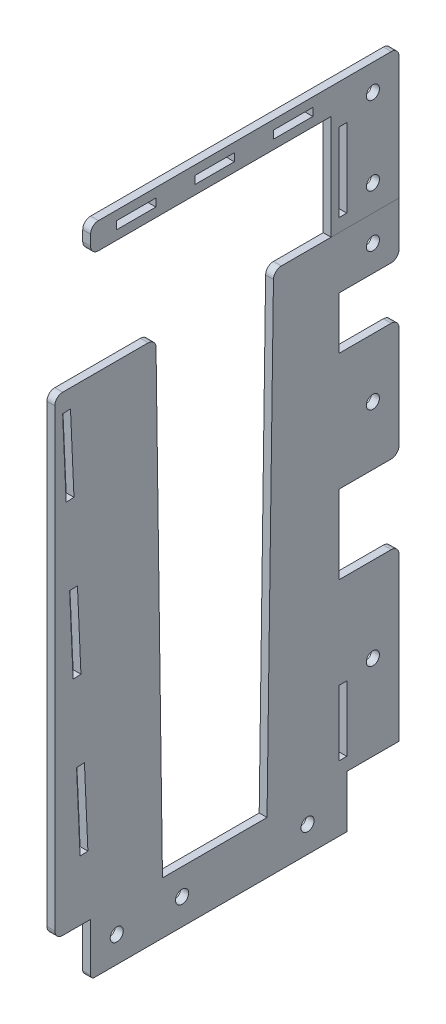
from build123d import *

# Parameters (mm, degrees)
SKETCH1_R           = 2.5
SKETCH1_W           = 3
SKETCH1_H           = 25
BOSS_EXTRUDE1_DEPTH = 3
SKETCH4_W           = 15
SKETCH4_H           = 3
BOSS_EXTRUDE2_DEPTH = 3
SKETCH5_W           = 13.685275767
SKETCH5_H           = 180
BOSS_EXTRUDE3_DEPTH = 3
CUT_EXTRUDE3_DEPTH  = 4
FILLET1_R           = 3
SKETCH12_R          = 2.5
CUT_EXTRUDE7_DEPTH  = 4
FILLET2_R           = 1.5
SKETCH13_R          = 2.5
CUT_EXTRUDE8_DEPTH  = 4
SKETCH15_R          = 2.5
CUT_EXTRUDE9_DEPTH  = 10
SKETCH17_W          = 3
SKETCH17_H          = 30
CUT_EXTRUDE10_DEPTH = 4
SKETCH16_W          = 3
SKETCH16_H          = 40
BOSS_EXTRUDE4_DEPTH = 3
FILLET3_R           = 3


with BuildPart() as part:
    # Sketch1 → Boss-Extrude1 (new body)
    with BuildSketch(Plane(origin=(0, 0, 0), x_dir=(0, 0, -1), z_dir=(1, 0, 0))):
        Polygon((0, 0), (-98, 0), (-98, 200), (20, 200), (20, 180), (-3, 180), (-3, 160), (20, 160), (20, 115), (-3, 115), (-3, 85), (20, 85), (20, 20), (0, 20), align=None)
        with Locations((10, 190)):
            Circle(SKETCH1_R, mode=Mode.SUBTRACT)
        with Locations((10, 137.5)):
            Circle(SKETCH1_R, mode=Mode.SUBTRACT)
        with Locations((10, 52.5)):
            Circle(SKETCH1_R, mode=Mode.SUBTRACT)
        with Locations((-1.5, 37.5)):
            Rectangle(SKETCH1_W, SKETCH1_H, mode=Mode.SUBTRACT)
    extrude(amount=BOSS_EXTRUDE1_DEPTH)

    # Sketch5 → Boss-Extrude3 (add)
    with BuildSketch(Plane(origin=(3, 0, 0), x_dir=(0, 0, -1), z_dir=(1, 0, 0))):
        with Locations((-104.842637884, 110)):
            Rectangle(SKETCH5_W, SKETCH5_H)
        Polygon((-105.688234347, 192.985272811), (-108.685275767, 192.85207097), (-107.353257358, 162.881656776), (-104.356215939, 163.014858617), align=None, mode=Mode.SUBTRACT)
        Polygon((-103.02419753, 133.044444423), (-106.021238949, 132.911242582), (-104.689220541, 102.940828388), (-101.692179121, 103.074030229), align=None, mode=Mode.SUBTRACT)
        Polygon((-100.360160713, 73.103616035), (-103.357202132, 72.970414194), (-102.025183723, 43), (-99.028142304, 43.133201841), align=None, mode=Mode.SUBTRACT)
    extrude(amount=-BOSS_EXTRUDE3_DEPTH)

    # Sketch6 → Cut-Extrude3 (cut)
    with BuildSketch(Plane(origin=(3, 0, 0), x_dir=(0, 0, -1), z_dir=(1, 0, 0))):
        Polygon((-28, 200), (-73, 200), (-70.5, 20), (-30.5, 20), align=None)
    extrude(amount=-CUT_EXTRUDE3_DEPTH, mode=Mode.SUBTRACT)

    # Fillet1
    fillet1_edges = [part.edges().sort_by_distance(p)[0] for p in [
        (1.5, 200, 28),
        (1.5, 200, 73),
        (1.5, 180, -20),
        (1.5, 160, -20),
        (1.5, 115, -20),
        (1.5, 85, -20),
        (1.5, 20, 111.685275767),
        (1.5, 200, 111.685275767),
    ]]
    fillet(fillet1_edges, radius=FILLET1_R)

    # Sketch12 → Cut-Extrude7 (cut)
    with BuildSketch(Plane(origin=(3, 0, 0), x_dir=(0, 0, -1), z_dir=(1, 0, 0))):
        with Locations((-88, 10)):
            Circle(SKETCH12_R)
    extrude(amount=-CUT_EXTRUDE7_DEPTH, mode=Mode.SUBTRACT)

    # Fillet2
    fillet2_edges = [part.edges().sort_by_distance(p)[0] for p in [
        (1.5, 0, 98),
    ]]
    fillet(fillet2_edges, radius=FILLET2_R)

    # Sketch13 → Cut-Extrude8 (cut, through all)
    with BuildSketch(Plane(origin=(3, 0, 0), x_dir=(0, 0, -1), z_dir=(1, 0, 0))):
        with Locations((-63, 10)):
            Circle(SKETCH13_R)
        with Locations((-15, 10)):
            Circle(SKETCH13_R)
    extrude(amount=-CUT_EXTRUDE8_DEPTH, mode=Mode.SUBTRACT)


with BuildPart() as body_2:
    # Sketch4 → Boss-Extrude2 (new body)
    with BuildSketch(Plane(origin=(3, 0, 0), x_dir=(0, 0, -1), z_dir=(1, 0, 0))):
        Polygon((-98, 240), (-3, 240), (-3, 200), (20, 200), (20, 250), (-3, 250), (-98, 250), align=None)
        with Locations((-80.5, 245)):
            Rectangle(SKETCH4_W, SKETCH4_H, mode=Mode.SUBTRACT)
        with Locations((-50.5, 245)):
            Rectangle(SKETCH4_W, SKETCH4_H, mode=Mode.SUBTRACT)
        with Locations((-20.5, 245)):
            Rectangle(SKETCH4_W, SKETCH4_H, mode=Mode.SUBTRACT)
    extrude(amount=-BOSS_EXTRUDE2_DEPTH)

    # Sketch15 → Cut-Extrude9 (cut)
    with BuildSketch(Plane(origin=(3, 0, 0), x_dir=(0, 0, -1), z_dir=(1, 0, 0))):
        with Locations((10, 240)):
            Circle(SKETCH15_R)
        with Locations((10, 210)):
            Circle(SKETCH15_R)
    extrude(amount=-CUT_EXTRUDE9_DEPTH, mode=Mode.SUBTRACT)

    # Sketch17 → Cut-Extrude10 (cut, through all)
    with BuildSketch(Plane(origin=(3, 0, 0), x_dir=(0, 0, -1), z_dir=(1, 0, 0))):
        with Locations((-1.5, 220)):
            Rectangle(SKETCH17_W, SKETCH17_H)
    extrude(amount=-CUT_EXTRUDE10_DEPTH, mode=Mode.SUBTRACT)

    # Sketch16 → Boss-Extrude4 (add)
    with BuildSketch(Plane(origin=(3, 0, 0), x_dir=(0, 0, -1), z_dir=(1, 0, 0))):
        with Locations((-4.5, 220)):
            Rectangle(SKETCH16_W, SKETCH16_H)
    extrude(amount=-BOSS_EXTRUDE4_DEPTH)

    # Fillet3
    fillet3_edges = [body_2.edges().sort_by_distance(p)[0] for p in [
        (1.5, 240, 98),
        (1.5, 250, 98),
        (1.5, 250, -20),
    ]]
    fillet(fillet3_edges, radius=FILLET3_R)


solid = Compound([part.part, body_2.part])
